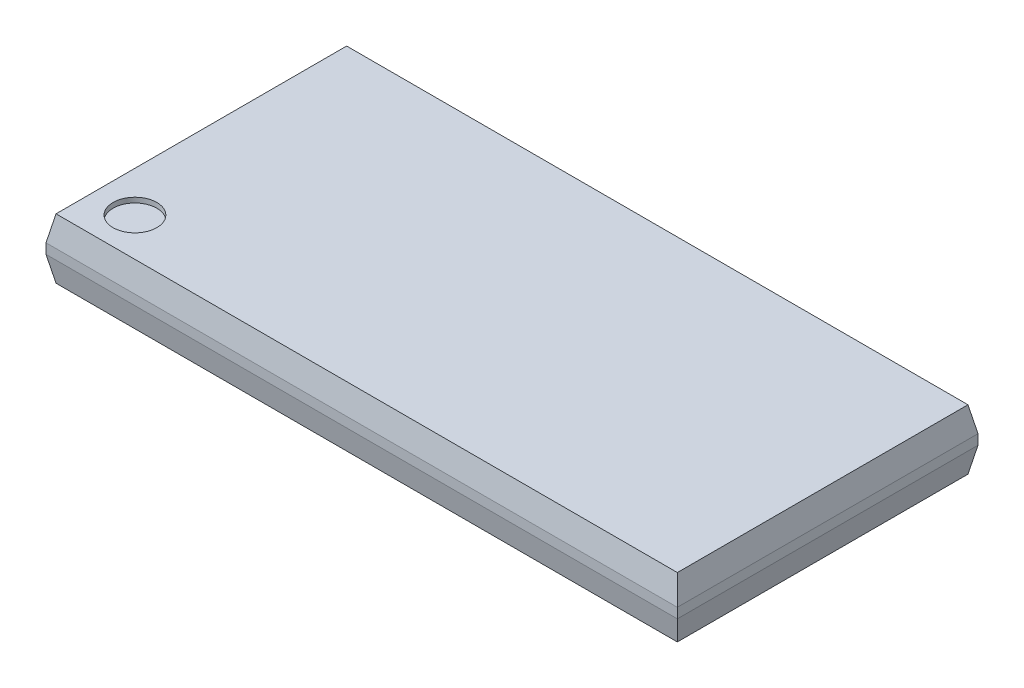
from build123d import *

# Parameters (mm, degrees)
ESQUISSE1_W             = 12.6
ESQUISSE1_H             = 6
BOSS_EXTRU_1_DEPTH      = 1.2
CHANFREIN1_SIZE         = 0.5
CHANFREIN1_SIZE2        = 0.1
CHANFREIN2_SIZE         = 0.1
CHANFREIN2_SIZE2        = 0.5
CHANFREIN3_SIZE         = 0.5
CHANFREIN3_SIZE2        = 0.1
CHANFREIN4_SIZE         = 0.1
CHANFREIN4_SIZE2        = 0.5
CHANFREIN5_SIZE         = 0.5
CHANFREIN5_SIZE2        = 0.1
CHANFREIN6_SIZE         = 0.1
CHANFREIN6_SIZE2        = 0.5
CHANFREIN7_SIZE         = 0.5
CHANFREIN7_SIZE2        = 0.1
CHANFREIN8_SIZE         = 0.1
CHANFREIN8_SIZE2        = 0.5
ESQUISSE2_R             = 0.436243036
ENL_V_MAT_EXTRU_1_DEPTH = 0.1


with BuildPart() as part:
    # Esquisse1 → Boss.-Extru.1 (new body)
    with BuildSketch(Plane(origin=(0, 0, 0), x_dir=(1, 0, 0), z_dir=(0, 1, 0))):
        with Locations((6.3, 3)):
            Rectangle(ESQUISSE1_W, ESQUISSE1_H)
    extrude(amount=BOSS_EXTRU_1_DEPTH)

    # Chanfrein1
    chanfrein1_edges = [part.edges().sort_by_distance(p)[0] for p in [
        (6.3, 1.2, 0),
    ]]
    chanfrein1_side = [part.faces().sort_by_distance(p)[0] for p in [
        (6.3, 0.6, 0),
    ]]
    chamfer(chanfrein1_edges, length=CHANFREIN1_SIZE, length2=CHANFREIN1_SIZE2, reference=chanfrein1_side[0])

    # Chanfrein2
    chanfrein2_edges = [part.edges().sort_by_distance(p)[0] for p in [
        (6.3, 0, 0),
    ]]
    chanfrein2_side = [part.faces().sort_by_distance(p)[0] for p in [
        (6.3, 0, -3),
    ]]
    chamfer(chanfrein2_edges, length=CHANFREIN2_SIZE, length2=CHANFREIN2_SIZE2, reference=chanfrein2_side[0])

    # Chanfrein3
    chanfrein3_edges = [part.edges().sort_by_distance(p)[0] for p in [
        (6.3, 1.2, -6),
    ]]
    chanfrein3_side = [part.faces().sort_by_distance(p)[0] for p in [
        (6.3, 0.6, -6),
    ]]
    chamfer(chanfrein3_edges, length=CHANFREIN3_SIZE, length2=CHANFREIN3_SIZE2, reference=chanfrein3_side[0])

    # Chanfrein4
    chanfrein4_edges = [part.edges().sort_by_distance(p)[0] for p in [
        (6.3, 0, -6),
    ]]
    chanfrein4_side = [part.faces().sort_by_distance(p)[0] for p in [
        (6.3, 0, -3.05),
    ]]
    chamfer(chanfrein4_edges, length=CHANFREIN4_SIZE, length2=CHANFREIN4_SIZE2, reference=chanfrein4_side[0])

    # Chanfrein5
    chanfrein5_edges = [part.edges().sort_by_distance(p)[0] for p in [
        (0, 1.2, -3),
    ]]
    chanfrein5_side = [part.faces().sort_by_distance(p)[0] for p in [
        (0, 0.6, -3),
    ]]
    chamfer(chanfrein5_edges, length=CHANFREIN5_SIZE, length2=CHANFREIN5_SIZE2, reference=chanfrein5_side[0])

    # Chanfrein6
    chanfrein6_edges = [part.edges().sort_by_distance(p)[0] for p in [
        (0, 0, -3),
    ]]
    chanfrein6_side = [part.faces().sort_by_distance(p)[0] for p in [
        (6.3, 0, -3),
    ]]
    chamfer(chanfrein6_edges, length=CHANFREIN6_SIZE, length2=CHANFREIN6_SIZE2, reference=chanfrein6_side[0])

    # Chanfrein7
    chanfrein7_edges = [part.edges().sort_by_distance(p)[0] for p in [
        (12.6, 1.2, -3),
    ]]
    chanfrein7_side = [part.faces().sort_by_distance(p)[0] for p in [
        (12.6, 0.6, -3),
    ]]
    chamfer(chanfrein7_edges, length=CHANFREIN7_SIZE, length2=CHANFREIN7_SIZE2, reference=chanfrein7_side[0])

    # Chanfrein8
    chanfrein8_edges = [part.edges().sort_by_distance(p)[0] for p in [
        (12.6, 0, -3),
    ]]
    chanfrein8_side = [part.faces().sort_by_distance(p)[0] for p in [
        (6.35, 0, -3),
    ]]
    chamfer(chanfrein8_edges, length=CHANFREIN8_SIZE, length2=CHANFREIN8_SIZE2, reference=chanfrein8_side[0])

    # Esquisse2 → Enlèv. mat.-Extru.1 (cut)
    with BuildSketch(Plane(origin=(0, 1.2, 0), x_dir=(-1, 0, 0), z_dir=(0, 1, 0))):
        with Locations(Location((-0.908756143, -0.866244747, 0), (0, 0, 90))):  # turned: the seam where the file's is
            Circle(ESQUISSE2_R)
    extrude(amount=-ENL_V_MAT_EXTRU_1_DEPTH, mode=Mode.SUBTRACT)


solid = part.part
